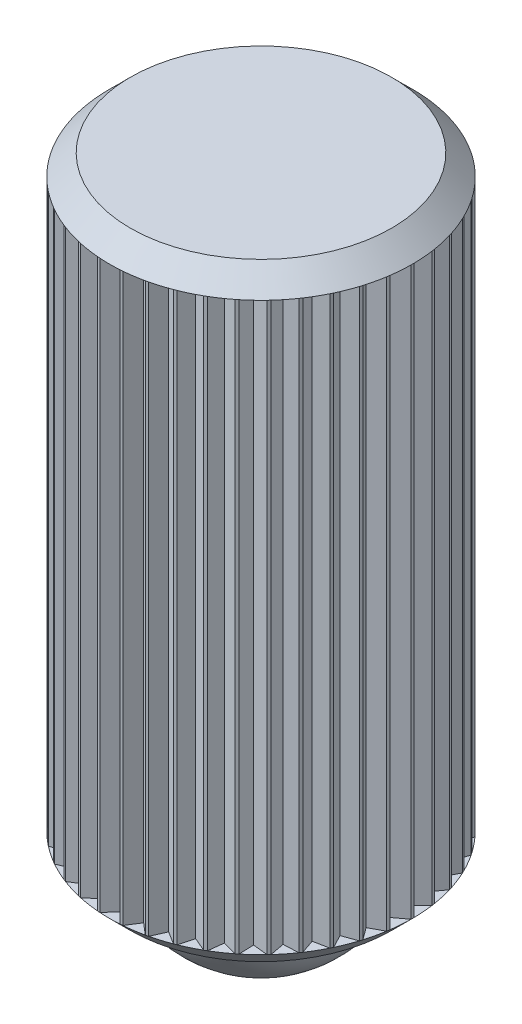
from build123d import *

# Parameters (mm, degrees)
EXTRUDE1_DEPTH    = 12.3063
CIRPATTERN1_COUNT = 42


with BuildPart() as part:
    # Sketch24 → Revolve2 (revolve)
    with BuildSketch(Plane(origin=(0, 0, 0), x_dir=(0, 0, -1), z_dir=(1, 0, 0))):
        Polygon((-2.83845, -5.715), (-3.2893, -5.26415), (-3.2893, 7.04215), (-2.83845, 7.493), (0, 7.493), (0, -4.123266667), (-2.3876, -4.123266667), (-2.3876, -5.715), align=None)
    revolve(axis=Axis((0, 7.493, 0), (0, -1, 0)))

    # Sketch26 → Extrude1 (cut)
    with BuildSketch(Plane(origin=(0, -5.26415, 0), x_dir=(-1, 0, 0), z_dir=(0, 1, 0))):
        with BuildLine():
            Line((0, 3.0353), (0.215130513, 3.282257356))
            ThreePointArc((0.215130513, 3.282257356), (0, 3.2893), (-0.215130513, 3.282257356))
            Line((-0.215130513, 3.282257356), (0, 3.0353))
        make_face()
    extrude1 = extrude(amount=EXTRUDE1_DEPTH, mode=Mode.SUBTRACT)

    # CirPattern1: Extrude1 ×42 about axis
    cirpattern1_axis = Axis((0, 0, 0), (0, 1, 0))
    for i in range(1, CIRPATTERN1_COUNT):
        add(extrude1.rotate(cirpattern1_axis, i * 360 / CIRPATTERN1_COUNT), mode=Mode.SUBTRACT)


with BuildPart() as body_2:
    # Sketch25 → Revolve3 (revolve)
    with BuildSketch(Plane(origin=(0, 0, 0), x_dir=(0, 0, -1), z_dir=(1, 0, 0))):
        with BuildLine():
            Line((0, -7.493), (0, -2.7178))
            ThreePointArc((0, -2.7178), (-2.3876, -5.1054), (0, -7.493))
        make_face()
    revolve(axis=Axis((0, -4.123266667, 0), (0, 1, 0)))


solid = Compound([part.part, body_2.part])
